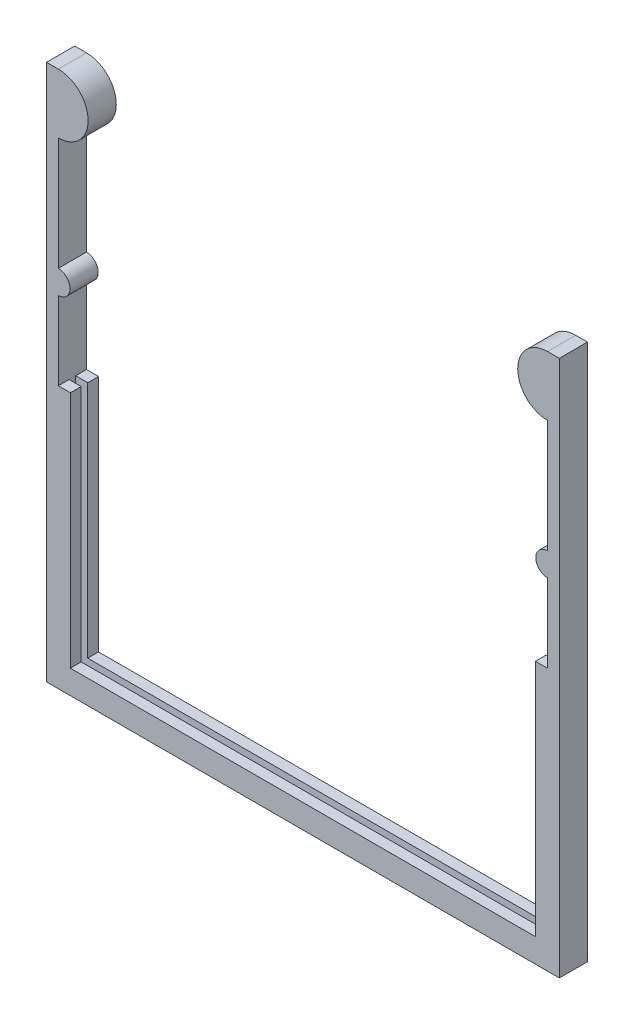
from build123d import *

# Parameters (mm, degrees)
BOSS_EXTRUDE1_DEPTH      = 3
BOSS_EXTRUDE1_DEPTH_BACK = 3
CUT_EXTRUDE1_DEPTH       = 0.7
CUT_EXTRUDE1_DEPTH_BACK  = 0.7


with BuildPart() as part:
    # Sketch2 → Boss-Extrude1 (new, two sides: drawn at the far end of the back side and taken through both)
    with BuildSketch(Plane.XY.offset(-BOSS_EXTRUDE1_DEPTH_BACK)):
        with BuildLine():
            Line((-52.1, 67.96), (-54.61, 67.96))
            Line((-54.61, 67.96), (-54.61, 9.929230009))
            Line((-54.61, 9.929230009), (-54.61, -46.34))
            Line((-54.61, -46.34), (54.61, -46.34))
            Line((54.61, -46.34), (54.61, 9.929230009))
            Line((54.61, 9.929230009), (54.61, 67.96))
            Line((54.61, 67.96), (52.1, 67.96))
            ThreePointArc((52.1, 67.96), (45.75, 61.61), (52.1, 55.26))
            Line((52.1, 55.26), (52.1, 43.8))
            Line((52.1, 43.8), (52.1, 31.2))
            ThreePointArc((52.1, 31.2), (49.6, 28.7), (52.1, 26.2))
            Line((52.1, 26.2), (52.1, 9.54))
            Line((52.1, 9.54), (49.53, 9.54))
            Line((49.53, 9.54), (49.53, -41.26))
            Line((49.53, -41.26), (-49.53, -41.26))
            Line((-49.53, -41.26), (-49.53, 9.54))
            Line((-49.53, 9.54), (-52.1, 9.54))
            Line((-52.1, 9.54), (-52.1, 26.2))
            ThreePointArc((-52.1, 26.2), (-49.6, 28.7), (-52.1, 31.2))
            Line((-52.1, 31.2), (-52.1, 43.8))
            Line((-52.1, 43.8), (-52.1, 55.26))
            ThreePointArc((-52.1, 55.26), (-45.75, 61.61), (-52.1, 67.96))
        make_face()
    extrude(amount=BOSS_EXTRUDE1_DEPTH + BOSS_EXTRUDE1_DEPTH_BACK)

    # Sketch3 → Cut-Extrude1 (cut, two sides: drawn at the far end of the back side and taken through both)
    with BuildSketch(Plane.XY.offset(-CUT_EXTRUDE1_DEPTH_BACK)):
        Polygon((-52.1, 9.54), (-52.1, -43.8), (52.1, -43.8), (52.1, 9.54), (49.53, 9.54), (-49.53, 9.54), align=None)
    extrude(amount=CUT_EXTRUDE1_DEPTH + CUT_EXTRUDE1_DEPTH_BACK, mode=Mode.SUBTRACT)


solid = part.part
